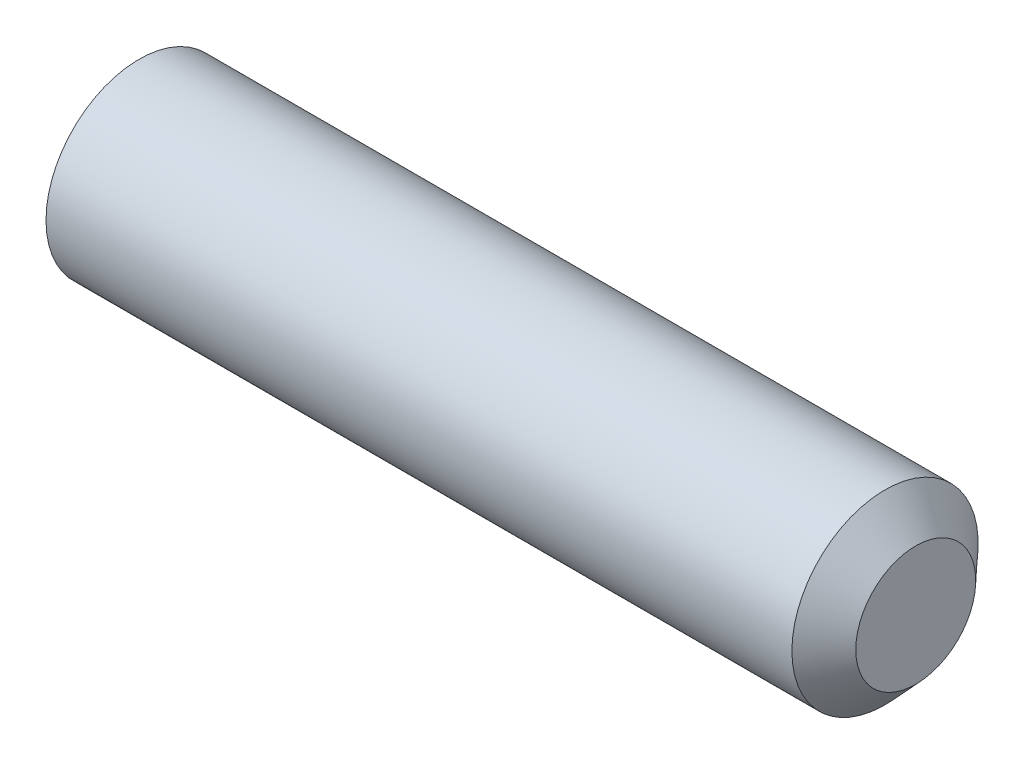
from build123d import *


with BuildPart() as part:
    # Sketch1 → Revolve1 (revolve)
    with BuildSketch(Plane(origin=(0, 0, 0), x_dir=(1, 0, 0), z_dir=(0, 1, 0))):
        Polygon((-49.75, 0), (-49.75, 12.425), (49.75, 12.425), (53.85, 8), (53.85, 0), align=None)
    revolve(axis=Axis((0, 0, 0), (1, 0, 0)))


solid = part.part
